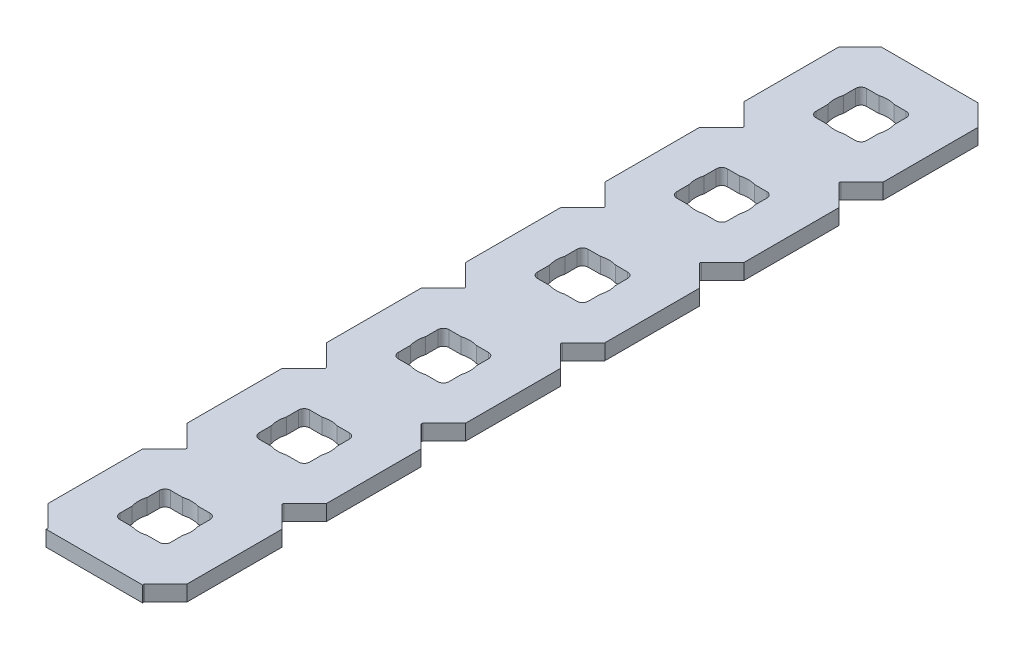
from build123d import *

# Parameters (mm, degrees)
BOSS_EXTRUDE1_DEPTH = 1.4224
SKETCH2_R           = 2.413
CUT_EXTRUDE1_DEPTH  = 2.54
LPATTERN1_COUNT     = 25
LPATTERN1_PITCH     = 12.7
SKETCH3_W           = 12.7
SKETCH3_H           = 63.589802561
CUT_EXTRUDE2_DEPTH  = 2.4224
SKETCH4_W           = 31.160114054
SKETCH4_H           = 185.655670282
CUT_EXTRUDE3_DEPTH  = 2.54


with BuildPart() as part:
    # Sketch1 → Boss-Extrude1 (new body)
    with BuildSketch(Plane.XZ):
        with BuildLine():
            Line((12.7, -302.773014945), (12.7, -294.126985055))
            Line((12.7, -294.126985055), (10.762817506, -292.189802561))
            ThreePointArc((10.762817506, -292.189802561), (10.725620068, -292.1), (10.762817506, -292.010197439))
            Line((10.762817506, -292.010197439), (12.7, -290.073014945))
            Line((12.7, -290.073014945), (12.7, -281.426985055))
            Line((12.7, -281.426985055), (10.762817506, -279.489802561))
            ThreePointArc((10.762817506, -279.489802561), (10.725620068, -279.4), (10.762817506, -279.310197439))
            Line((10.762817506, -279.310197439), (12.7, -277.373014945))
            Line((12.7, -277.373014945), (12.7, -268.726985055))
            Line((12.7, -268.726985055), (10.762817506, -266.789802561))
            ThreePointArc((10.762817506, -266.789802561), (10.725620068, -266.7), (10.762817506, -266.610197439))
            Line((10.762817506, -266.610197439), (12.7, -264.673014945))
            Line((12.7, -264.673014945), (12.7, -256.026985055))
            Line((12.7, -256.026985055), (10.762817506, -254.089802561))
            ThreePointArc((10.762817506, -254.089802561), (10.725620068, -254), (10.762817506, -253.910197439))
            Line((10.762817506, -253.910197439), (12.7, -251.973014945))
            Line((12.7, -251.973014945), (12.7, -243.326985055))
            Line((12.7, -243.326985055), (10.762817506, -241.389802561))
            ThreePointArc((10.762817506, -241.389802561), (10.725620068, -241.3), (10.762817506, -241.210197439))
            Line((10.762817506, -241.210197439), (12.7, -239.273014945))
            Line((12.7, -239.273014945), (12.7, -230.626985055))
            Line((12.7, -230.626985055), (10.762817506, -228.689802561))
            ThreePointArc((10.762817506, -228.689802561), (10.725620068, -228.6), (10.762817506, -228.510197439))
            Line((10.762817506, -228.510197439), (12.7, -226.573014945))
            Line((12.7, -226.573014945), (12.7, -217.926985055))
            Line((12.7, -217.926985055), (10.762817506, -215.989802561))
            ThreePointArc((10.762817506, -215.989802561), (10.725620068, -215.9), (10.762817506, -215.810197439))
            Line((10.762817506, -215.810197439), (12.7, -213.873014945))
            Line((12.7, -213.873014945), (12.7, -205.226985055))
            Line((12.7, -205.226985055), (10.762817506, -203.289802561))
            ThreePointArc((10.762817506, -203.289802561), (10.725620068, -203.2), (10.762817506, -203.110197439))
            Line((10.762817506, -203.110197439), (12.7, -201.173014945))
            Line((12.7, -201.173014945), (12.7, -192.526985055))
            Line((12.7, -192.526985055), (10.762817506, -190.589802561))
            ThreePointArc((10.762817506, -190.589802561), (10.725620068, -190.5), (10.762817506, -190.410197439))
            Line((10.762817506, -190.410197439), (12.7, -188.473014945))
            Line((12.7, -188.473014945), (12.7, -179.826985055))
            Line((12.7, -179.826985055), (10.762817506, -177.889802561))
            ThreePointArc((10.762817506, -177.889802561), (10.725620068, -177.8), (10.762817506, -177.710197439))
            Line((10.762817506, -177.710197439), (12.7, -175.773014945))
            Line((12.7, -175.773014945), (12.7, -167.126985055))
            Line((12.7, -167.126985055), (10.762817506, -165.189802561))
            ThreePointArc((10.762817506, -165.189802561), (10.725620068, -165.1), (10.762817506, -165.010197439))
            Line((10.762817506, -165.010197439), (12.7, -163.073014945))
            Line((12.7, -163.073014945), (12.7, -154.426985055))
            Line((12.7, -154.426985055), (10.762817506, -152.489802561))
            ThreePointArc((10.762817506, -152.489802561), (10.725620068, -152.4), (10.762817506, -152.310197439))
            Line((10.762817506, -152.310197439), (12.7, -150.373014945))
            Line((12.7, -150.373014945), (12.7, -141.726985055))
            Line((12.7, -141.726985055), (10.762817506, -139.789802561))
            ThreePointArc((10.762817506, -139.789802561), (10.725620068, -139.7), (10.762817506, -139.610197439))
            Line((10.762817506, -139.610197439), (12.7, -137.673014945))
            Line((12.7, -137.673014945), (12.7, -129.026985055))
            Line((12.7, -129.026985055), (10.762817506, -127.089802561))
            ThreePointArc((10.762817506, -127.089802561), (10.725620068, -127), (10.762817506, -126.910197439))
            Line((10.762817506, -126.910197439), (12.7, -124.973014945))
            Line((12.7, -124.973014945), (12.7, -116.326985055))
            Line((12.7, -116.326985055), (10.762817506, -114.389802561))
            ThreePointArc((10.762817506, -114.389802561), (10.725620068, -114.3), (10.762817506, -114.210197439))
            Line((10.762817506, -114.210197439), (12.7, -112.273014945))
            Line((12.7, -112.273014945), (12.7, -103.626985055))
            Line((12.7, -103.626985055), (10.762817506, -101.689802561))
            ThreePointArc((10.762817506, -101.689802561), (10.725620068, -101.6), (10.762817506, -101.510197439))
            Line((10.762817506, -101.510197439), (12.7, -99.573014945))
            Line((12.7, -99.573014945), (12.7, -90.926985055))
            Line((12.7, -90.926985055), (10.762817506, -88.989802561))
            ThreePointArc((10.762817506, -88.989802561), (10.725620068, -88.9), (10.762817506, -88.810197439))
            Line((10.762817506, -88.810197439), (12.7, -86.873014945))
            Line((12.7, -86.873014945), (12.7, -78.226985055))
            Line((12.7, -78.226985055), (10.762817506, -76.289802561))
            ThreePointArc((10.762817506, -76.289802561), (10.725620068, -76.2), (10.762817506, -76.110197439))
            Line((10.762817506, -76.110197439), (12.7, -74.173014945))
            Line((12.7, -74.173014945), (12.7, -65.526985055))
            Line((12.7, -65.526985055), (10.762817506, -63.589802561))
            ThreePointArc((10.762817506, -63.589802561), (10.725620068, -63.5), (10.762817506, -63.410197439))
            Line((10.762817506, -63.410197439), (12.7, -61.473014945))
            Line((12.7, -61.473014945), (12.7, -52.826985055))
            Line((12.7, -52.826985055), (10.762817506, -50.889802561))
            ThreePointArc((10.762817506, -50.889802561), (10.725620068, -50.8), (10.762817506, -50.710197439))
            Line((10.762817506, -50.710197439), (12.7, -48.773014945))
            Line((12.7, -48.773014945), (12.7, -40.126985055))
            Line((12.7, -40.126985055), (10.762817506, -38.189802561))
            ThreePointArc((10.762817506, -38.189802561), (10.725620068, -38.1), (10.762817506, -38.010197439))
            Line((10.762817506, -38.010197439), (12.7, -36.073014945))
            Line((12.7, -36.073014945), (12.7, -27.426985055))
            Line((12.7, -27.426985055), (10.762817506, -25.489802561))
            ThreePointArc((10.762817506, -25.489802561), (10.725620068, -25.4), (10.762817506, -25.310197439))
            Line((10.762817506, -25.310197439), (12.7, -23.373014945))
            Line((12.7, -23.373014945), (12.7, -14.726985055))
            Line((12.7, -14.726985055), (10.762817506, -12.789802561))
            ThreePointArc((10.762817506, -12.789802561), (10.725620068, -12.7), (10.762817506, -12.610197439))
            Line((10.762817506, -12.610197439), (12.7, -10.673014945))
            Line((12.7, -10.673014945), (12.7, -2.032))
            Line((12.7, -2.032), (10.668, 0))
            Line((10.668, 0), (2.032, 0))
            Line((2.032, 0), (0, -2.032))
            Line((0, -2.032), (0, -10.673014945))
            Line((0, -10.673014945), (1.937182494, -12.610197439))
            ThreePointArc((1.937182494, -12.610197439), (1.974379932, -12.7), (1.937182494, -12.789802561))
            Line((1.937182494, -12.789802561), (0, -14.726985055))
            Line((0, -14.726985055), (0, -23.373014945))
            Line((0, -23.373014945), (1.937182494, -25.310197439))
            ThreePointArc((1.937182494, -25.310197439), (1.974379932, -25.4), (1.937182494, -25.489802561))
            Line((1.937182494, -25.489802561), (0, -27.426985055))
            Line((0, -27.426985055), (0, -36.073014945))
            Line((0, -36.073014945), (1.937182494, -38.010197439))
            ThreePointArc((1.937182494, -38.010197439), (1.974379932, -38.1), (1.937182494, -38.189802561))
            Line((1.937182494, -38.189802561), (0, -40.126985055))
            Line((0, -40.126985055), (0, -48.773014945))
            Line((0, -48.773014945), (1.937182494, -50.710197439))
            ThreePointArc((1.937182494, -50.710197439), (1.974379932, -50.8), (1.937182494, -50.889802561))
            Line((1.937182494, -50.889802561), (0, -52.826985055))
            Line((0, -52.826985055), (0, -61.473014945))
            Line((0, -61.473014945), (1.937182494, -63.410197439))
            ThreePointArc((1.937182494, -63.410197439), (1.974379932, -63.5), (1.937182494, -63.589802561))
            Line((1.937182494, -63.589802561), (0, -65.526985055))
            Line((0, -65.526985055), (0, -74.173014945))
            Line((0, -74.173014945), (1.937182494, -76.110197439))
            ThreePointArc((1.937182494, -76.110197439), (1.974379932, -76.2), (1.937182494, -76.289802561))
            Line((1.937182494, -76.289802561), (0, -78.226985055))
            Line((0, -78.226985055), (0, -86.873014945))
            Line((0, -86.873014945), (1.937182494, -88.810197439))
            ThreePointArc((1.937182494, -88.810197439), (1.974379932, -88.9), (1.937182494, -88.989802561))
            Line((1.937182494, -88.989802561), (0, -90.926985055))
            Line((0, -90.926985055), (0, -99.573014945))
            Line((0, -99.573014945), (1.937182494, -101.510197439))
            ThreePointArc((1.937182494, -101.510197439), (1.974379932, -101.6), (1.937182494, -101.689802561))
            Line((1.937182494, -101.689802561), (0, -103.626985055))
            Line((0, -103.626985055), (0, -112.273014945))
            Line((0, -112.273014945), (1.937182494, -114.210197439))
            ThreePointArc((1.937182494, -114.210197439), (1.974379932, -114.3), (1.937182494, -114.389802561))
            Line((1.937182494, -114.389802561), (0, -116.326985055))
            Line((0, -116.326985055), (0, -124.973014945))
            Line((0, -124.973014945), (1.937182494, -126.910197439))
            ThreePointArc((1.937182494, -126.910197439), (1.974379932, -127), (1.937182494, -127.089802561))
            Line((1.937182494, -127.089802561), (0, -129.026985055))
            Line((0, -129.026985055), (0, -137.673014945))
            Line((0, -137.673014945), (1.937182494, -139.610197439))
            ThreePointArc((1.937182494, -139.610197439), (1.974379932, -139.7), (1.937182494, -139.789802561))
            Line((1.937182494, -139.789802561), (0, -141.726985055))
            Line((0, -141.726985055), (0, -150.373014945))
            Line((0, -150.373014945), (1.937182494, -152.310197439))
            ThreePointArc((1.937182494, -152.310197439), (1.974379932, -152.4), (1.937182494, -152.489802561))
            Line((1.937182494, -152.489802561), (0, -154.426985055))
            Line((0, -154.426985055), (0, -163.073014945))
            Line((0, -163.073014945), (1.937182494, -165.010197439))
            ThreePointArc((1.937182494, -165.010197439), (1.974379932, -165.1), (1.937182494, -165.189802561))
            Line((1.937182494, -165.189802561), (0, -167.126985055))
            Line((0, -167.126985055), (0, -175.773014945))
            Line((0, -175.773014945), (1.937182494, -177.710197439))
            ThreePointArc((1.937182494, -177.710197439), (1.974379932, -177.8), (1.937182494, -177.889802561))
            Line((1.937182494, -177.889802561), (0, -179.826985055))
            Line((0, -179.826985055), (0, -188.473014945))
            Line((0, -188.473014945), (1.937182494, -190.410197439))
            ThreePointArc((1.937182494, -190.410197439), (1.974379932, -190.5), (1.937182494, -190.589802561))
            Line((1.937182494, -190.589802561), (0, -192.526985055))
            Line((0, -192.526985055), (0, -201.173014945))
            Line((0, -201.173014945), (1.937182494, -203.110197439))
            ThreePointArc((1.937182494, -203.110197439), (1.974379932, -203.2), (1.937182494, -203.289802561))
            Line((1.937182494, -203.289802561), (0, -205.226985055))
            Line((0, -205.226985055), (0, -213.873014945))
            Line((0, -213.873014945), (1.937182494, -215.810197439))
            ThreePointArc((1.937182494, -215.810197439), (1.974379932, -215.9), (1.937182494, -215.989802561))
            Line((1.937182494, -215.989802561), (0, -217.926985055))
            Line((0, -217.926985055), (0, -226.573014945))
            Line((0, -226.573014945), (1.937182494, -228.510197439))
            ThreePointArc((1.937182494, -228.510197439), (1.974379932, -228.6), (1.937182494, -228.689802561))
            Line((1.937182494, -228.689802561), (0, -230.626985055))
            Line((0, -230.626985055), (0, -239.273014945))
            Line((0, -239.273014945), (1.937182494, -241.210197439))
            ThreePointArc((1.937182494, -241.210197439), (1.974379932, -241.3), (1.937182494, -241.389802561))
            Line((1.937182494, -241.389802561), (0, -243.326985055))
            Line((0, -243.326985055), (0, -251.973014945))
            Line((0, -251.973014945), (1.937182494, -253.910197439))
            ThreePointArc((1.937182494, -253.910197439), (1.974379932, -254), (1.937182494, -254.089802561))
            Line((1.937182494, -254.089802561), (0, -256.026985055))
            Line((0, -256.026985055), (0, -264.673014945))
            Line((0, -264.673014945), (1.937182494, -266.610197439))
            ThreePointArc((1.937182494, -266.610197439), (1.974379932, -266.7), (1.937182494, -266.789802561))
            Line((1.937182494, -266.789802561), (0, -268.726985055))
            Line((0, -268.726985055), (0, -277.373014945))
            Line((0, -277.373014945), (1.937182494, -279.310197439))
            ThreePointArc((1.937182494, -279.310197439), (1.974379932, -279.4), (1.937182494, -279.489802561))
            Line((1.937182494, -279.489802561), (0, -281.426985055))
            Line((0, -281.426985055), (0, -290.073014945))
            Line((0, -290.073014945), (1.937182494, -292.010197439))
            ThreePointArc((1.937182494, -292.010197439), (1.974379932, -292.1), (1.937182494, -292.189802561))
            Line((1.937182494, -292.189802561), (0, -294.126985055))
            Line((0, -294.126985055), (0, -302.773014945))
            Line((0, -302.773014945), (1.937182494, -304.710197439))
            ThreePointArc((1.937182494, -304.710197439), (1.974379932, -304.8), (1.937182494, -304.889802561))
            Line((1.937182494, -304.889802561), (0, -306.826985055))
            Line((0, -306.826985055), (0, -315.468))
            Line((0, -315.468), (2.032, -317.5))
            Line((2.032, -317.5), (10.668, -317.5))
            Line((10.668, -317.5), (12.7, -315.468))
            Line((12.7, -315.468), (12.7, -306.826985055))
            Line((12.7, -306.826985055), (10.762817506, -304.889802561))
            ThreePointArc((10.762817506, -304.889802561), (10.725620068, -304.8), (10.762817506, -304.710197439))
            Line((10.762817506, -304.710197439), (12.7, -302.773014945))
        make_face()
        with BuildLine():
            Line((4.5466, -308.8386), (8.1534, -308.8386))
            ThreePointArc((8.1534, -308.8386), (8.512610245, -308.987389755), (8.6614, -309.3466))
            Line((8.6614, -309.3466), (8.6614, -312.9534))
            ThreePointArc((8.6614, -312.9534), (8.512610245, -313.312610245), (8.1534, -313.4614))
            Line((8.1534, -313.4614), (4.5466, -313.4614))
            ThreePointArc((4.5466, -313.4614), (4.187389755, -313.312610245), (4.0386, -312.9534))
            Line((4.0386, -312.9534), (4.0386, -309.3466))
            ThreePointArc((4.0386, -309.3466), (4.187389755, -308.987389755), (4.5466, -308.8386))
        make_face(mode=Mode.SUBTRACT)
        with BuildLine():
            Line((4.5466, -296.1386), (8.1534, -296.1386))
            ThreePointArc((8.1534, -296.1386), (8.512610245, -296.287389755), (8.6614, -296.6466))
            Line((8.6614, -296.6466), (8.6614, -300.2534))
            ThreePointArc((8.6614, -300.2534), (8.512610245, -300.612610245), (8.1534, -300.7614))
            Line((8.1534, -300.7614), (4.5466, -300.7614))
            ThreePointArc((4.5466, -300.7614), (4.187389755, -300.612610245), (4.0386, -300.2534))
            Line((4.0386, -300.2534), (4.0386, -296.6466))
            ThreePointArc((4.0386, -296.6466), (4.187389755, -296.287389755), (4.5466, -296.1386))
        make_face(mode=Mode.SUBTRACT)
        with BuildLine():
            Line((4.5466, -283.4386), (8.1534, -283.4386))
            ThreePointArc((8.1534, -283.4386), (8.512610245, -283.587389755), (8.6614, -283.9466))
            Line((8.6614, -283.9466), (8.6614, -287.5534))
            ThreePointArc((8.6614, -287.5534), (8.512610245, -287.912610245), (8.1534, -288.0614))
            Line((8.1534, -288.0614), (4.5466, -288.0614))
            ThreePointArc((4.5466, -288.0614), (4.187389755, -287.912610245), (4.0386, -287.5534))
            Line((4.0386, -287.5534), (4.0386, -283.9466))
            ThreePointArc((4.0386, -283.9466), (4.187389755, -283.587389755), (4.5466, -283.4386))
        make_face(mode=Mode.SUBTRACT)
        with BuildLine():
            Line((4.5466, -270.7386), (8.1534, -270.7386))
            ThreePointArc((8.1534, -270.7386), (8.512610245, -270.887389755), (8.6614, -271.2466))
            Line((8.6614, -271.2466), (8.6614, -274.8534))
            ThreePointArc((8.6614, -274.8534), (8.512610245, -275.212610245), (8.1534, -275.3614))
            Line((8.1534, -275.3614), (4.5466, -275.3614))
            ThreePointArc((4.5466, -275.3614), (4.187389755, -275.212610245), (4.0386, -274.8534))
            Line((4.0386, -274.8534), (4.0386, -271.2466))
            ThreePointArc((4.0386, -271.2466), (4.187389755, -270.887389755), (4.5466, -270.7386))
        make_face(mode=Mode.SUBTRACT)
        with BuildLine():
            Line((4.5466, -258.0386), (8.1534, -258.0386))
            ThreePointArc((8.1534, -258.0386), (8.512610245, -258.187389755), (8.6614, -258.5466))
            Line((8.6614, -258.5466), (8.6614, -262.1534))
            ThreePointArc((8.6614, -262.1534), (8.512610245, -262.512610245), (8.1534, -262.6614))
            Line((8.1534, -262.6614), (4.5466, -262.6614))
            ThreePointArc((4.5466, -262.6614), (4.187389755, -262.512610245), (4.0386, -262.1534))
            Line((4.0386, -262.1534), (4.0386, -258.5466))
            ThreePointArc((4.0386, -258.5466), (4.187389755, -258.187389755), (4.5466, -258.0386))
        make_face(mode=Mode.SUBTRACT)
        with BuildLine():
            Line((4.5466, -245.3386), (8.1534, -245.3386))
            ThreePointArc((8.1534, -245.3386), (8.512610245, -245.487389755), (8.6614, -245.8466))
            Line((8.6614, -245.8466), (8.6614, -249.4534))
            ThreePointArc((8.6614, -249.4534), (8.512610245, -249.812610245), (8.1534, -249.9614))
            Line((8.1534, -249.9614), (4.5466, -249.9614))
            ThreePointArc((4.5466, -249.9614), (4.187389755, -249.812610245), (4.0386, -249.4534))
            Line((4.0386, -249.4534), (4.0386, -245.8466))
            ThreePointArc((4.0386, -245.8466), (4.187389755, -245.487389755), (4.5466, -245.3386))
        make_face(mode=Mode.SUBTRACT)
        with BuildLine():
            Line((4.5466, -232.6386), (8.1534, -232.6386))
            ThreePointArc((8.1534, -232.6386), (8.512610245, -232.787389755), (8.6614, -233.1466))
            Line((8.6614, -233.1466), (8.6614, -236.7534))
            ThreePointArc((8.6614, -236.7534), (8.512610245, -237.112610245), (8.1534, -237.2614))
            Line((8.1534, -237.2614), (4.5466, -237.2614))
            ThreePointArc((4.5466, -237.2614), (4.187389755, -237.112610245), (4.0386, -236.7534))
            Line((4.0386, -236.7534), (4.0386, -233.1466))
            ThreePointArc((4.0386, -233.1466), (4.187389755, -232.787389755), (4.5466, -232.6386))
        make_face(mode=Mode.SUBTRACT)
        with BuildLine():
            Line((4.5466, -219.9386), (8.1534, -219.9386))
            ThreePointArc((8.1534, -219.9386), (8.512610245, -220.087389755), (8.6614, -220.4466))
            Line((8.6614, -220.4466), (8.6614, -224.0534))
            ThreePointArc((8.6614, -224.0534), (8.512610245, -224.412610245), (8.1534, -224.5614))
            Line((8.1534, -224.5614), (4.5466, -224.5614))
            ThreePointArc((4.5466, -224.5614), (4.187389755, -224.412610245), (4.0386, -224.0534))
            Line((4.0386, -224.0534), (4.0386, -220.4466))
            ThreePointArc((4.0386, -220.4466), (4.187389755, -220.087389755), (4.5466, -219.9386))
        make_face(mode=Mode.SUBTRACT)
        with BuildLine():
            Line((4.5466, -207.2386), (8.1534, -207.2386))
            ThreePointArc((8.1534, -207.2386), (8.512610245, -207.387389755), (8.6614, -207.7466))
            Line((8.6614, -207.7466), (8.6614, -211.3534))
            ThreePointArc((8.6614, -211.3534), (8.512610245, -211.712610245), (8.1534, -211.8614))
            Line((8.1534, -211.8614), (4.5466, -211.8614))
            ThreePointArc((4.5466, -211.8614), (4.187389755, -211.712610245), (4.0386, -211.3534))
            Line((4.0386, -211.3534), (4.0386, -207.7466))
            ThreePointArc((4.0386, -207.7466), (4.187389755, -207.387389755), (4.5466, -207.2386))
        make_face(mode=Mode.SUBTRACT)
        with BuildLine():
            Line((4.5466, -194.5386), (8.1534, -194.5386))
            ThreePointArc((8.1534, -194.5386), (8.512610245, -194.687389755), (8.6614, -195.0466))
            Line((8.6614, -195.0466), (8.6614, -198.6534))
            ThreePointArc((8.6614, -198.6534), (8.512610245, -199.012610245), (8.1534, -199.1614))
            Line((8.1534, -199.1614), (4.5466, -199.1614))
            ThreePointArc((4.5466, -199.1614), (4.187389755, -199.012610245), (4.0386, -198.6534))
            Line((4.0386, -198.6534), (4.0386, -195.0466))
            ThreePointArc((4.0386, -195.0466), (4.187389755, -194.687389755), (4.5466, -194.5386))
        make_face(mode=Mode.SUBTRACT)
        with BuildLine():
            Line((4.5466, -181.8386), (8.1534, -181.8386))
            ThreePointArc((8.1534, -181.8386), (8.512610245, -181.987389755), (8.6614, -182.3466))
            Line((8.6614, -182.3466), (8.6614, -185.9534))
            ThreePointArc((8.6614, -185.9534), (8.512610245, -186.312610245), (8.1534, -186.4614))
            Line((8.1534, -186.4614), (4.5466, -186.4614))
            ThreePointArc((4.5466, -186.4614), (4.187389755, -186.312610245), (4.0386, -185.9534))
            Line((4.0386, -185.9534), (4.0386, -182.3466))
            ThreePointArc((4.0386, -182.3466), (4.187389755, -181.987389755), (4.5466, -181.8386))
        make_face(mode=Mode.SUBTRACT)
        with BuildLine():
            Line((4.5466, -169.1386), (8.1534, -169.1386))
            ThreePointArc((8.1534, -169.1386), (8.512610245, -169.287389755), (8.6614, -169.6466))
            Line((8.6614, -169.6466), (8.6614, -173.2534))
            ThreePointArc((8.6614, -173.2534), (8.512610245, -173.612610245), (8.1534, -173.7614))
            Line((8.1534, -173.7614), (4.5466, -173.7614))
            ThreePointArc((4.5466, -173.7614), (4.187389755, -173.612610245), (4.0386, -173.2534))
            Line((4.0386, -173.2534), (4.0386, -169.6466))
            ThreePointArc((4.0386, -169.6466), (4.187389755, -169.287389755), (4.5466, -169.1386))
        make_face(mode=Mode.SUBTRACT)
        with BuildLine():
            Line((4.5466, -156.4386), (8.1534, -156.4386))
            ThreePointArc((8.1534, -156.4386), (8.512610245, -156.587389755), (8.6614, -156.9466))
            Line((8.6614, -156.9466), (8.6614, -160.5534))
            ThreePointArc((8.6614, -160.5534), (8.512610245, -160.912610245), (8.1534, -161.0614))
            Line((8.1534, -161.0614), (4.5466, -161.0614))
            ThreePointArc((4.5466, -161.0614), (4.187389755, -160.912610245), (4.0386, -160.5534))
            Line((4.0386, -160.5534), (4.0386, -156.9466))
            ThreePointArc((4.0386, -156.9466), (4.187389755, -156.587389755), (4.5466, -156.4386))
        make_face(mode=Mode.SUBTRACT)
        with BuildLine():
            Line((4.5466, -143.7386), (8.1534, -143.7386))
            ThreePointArc((8.1534, -143.7386), (8.512610245, -143.887389755), (8.6614, -144.2466))
            Line((8.6614, -144.2466), (8.6614, -147.8534))
            ThreePointArc((8.6614, -147.8534), (8.512610245, -148.212610245), (8.1534, -148.3614))
            Line((8.1534, -148.3614), (4.5466, -148.3614))
            ThreePointArc((4.5466, -148.3614), (4.187389755, -148.212610245), (4.0386, -147.8534))
            Line((4.0386, -147.8534), (4.0386, -144.2466))
            ThreePointArc((4.0386, -144.2466), (4.187389755, -143.887389755), (4.5466, -143.7386))
        make_face(mode=Mode.SUBTRACT)
        with BuildLine():
            Line((4.5466, -131.0386), (8.1534, -131.0386))
            ThreePointArc((8.1534, -131.0386), (8.512610245, -131.187389755), (8.6614, -131.5466))
            Line((8.6614, -131.5466), (8.6614, -135.1534))
            ThreePointArc((8.6614, -135.1534), (8.512610245, -135.512610245), (8.1534, -135.6614))
            Line((8.1534, -135.6614), (4.5466, -135.6614))
            ThreePointArc((4.5466, -135.6614), (4.187389755, -135.512610245), (4.0386, -135.1534))
            Line((4.0386, -135.1534), (4.0386, -131.5466))
            ThreePointArc((4.0386, -131.5466), (4.187389755, -131.187389755), (4.5466, -131.0386))
        make_face(mode=Mode.SUBTRACT)
        with BuildLine():
            Line((4.5466, -118.3386), (8.1534, -118.3386))
            ThreePointArc((8.1534, -118.3386), (8.512610245, -118.487389755), (8.6614, -118.8466))
            Line((8.6614, -118.8466), (8.6614, -122.4534))
            ThreePointArc((8.6614, -122.4534), (8.512610245, -122.812610245), (8.1534, -122.9614))
            Line((8.1534, -122.9614), (4.5466, -122.9614))
            ThreePointArc((4.5466, -122.9614), (4.187389755, -122.812610245), (4.0386, -122.4534))
            Line((4.0386, -122.4534), (4.0386, -118.8466))
            ThreePointArc((4.0386, -118.8466), (4.187389755, -118.487389755), (4.5466, -118.3386))
        make_face(mode=Mode.SUBTRACT)
        with BuildLine():
            Line((4.5466, -105.6386), (8.1534, -105.6386))
            ThreePointArc((8.1534, -105.6386), (8.512610245, -105.787389755), (8.6614, -106.1466))
            Line((8.6614, -106.1466), (8.6614, -109.7534))
            ThreePointArc((8.6614, -109.7534), (8.512610245, -110.112610245), (8.1534, -110.2614))
            Line((8.1534, -110.2614), (4.5466, -110.2614))
            ThreePointArc((4.5466, -110.2614), (4.187389755, -110.112610245), (4.0386, -109.7534))
            Line((4.0386, -109.7534), (4.0386, -106.1466))
            ThreePointArc((4.0386, -106.1466), (4.187389755, -105.787389755), (4.5466, -105.6386))
        make_face(mode=Mode.SUBTRACT)
        with BuildLine():
            Line((4.5466, -92.9386), (8.1534, -92.9386))
            ThreePointArc((8.1534, -92.9386), (8.512610245, -93.087389755), (8.6614, -93.4466))
            Line((8.6614, -93.4466), (8.6614, -97.0534))
            ThreePointArc((8.6614, -97.0534), (8.512610245, -97.412610245), (8.1534, -97.5614))
            Line((8.1534, -97.5614), (4.5466, -97.5614))
            ThreePointArc((4.5466, -97.5614), (4.187389755, -97.412610245), (4.0386, -97.0534))
            Line((4.0386, -97.0534), (4.0386, -93.4466))
            ThreePointArc((4.0386, -93.4466), (4.187389755, -93.087389755), (4.5466, -92.9386))
        make_face(mode=Mode.SUBTRACT)
        with BuildLine():
            Line((4.5466, -80.2386), (8.1534, -80.2386))
            ThreePointArc((8.1534, -80.2386), (8.512610245, -80.387389755), (8.6614, -80.7466))
            Line((8.6614, -80.7466), (8.6614, -84.3534))
            ThreePointArc((8.6614, -84.3534), (8.512610245, -84.712610245), (8.1534, -84.8614))
            Line((8.1534, -84.8614), (4.5466, -84.8614))
            ThreePointArc((4.5466, -84.8614), (4.187389755, -84.712610245), (4.0386, -84.3534))
            Line((4.0386, -84.3534), (4.0386, -80.7466))
            ThreePointArc((4.0386, -80.7466), (4.187389755, -80.387389755), (4.5466, -80.2386))
        make_face(mode=Mode.SUBTRACT)
        with BuildLine():
            Line((4.5466, -67.5386), (8.1534, -67.5386))
            ThreePointArc((8.1534, -67.5386), (8.512610245, -67.687389755), (8.6614, -68.0466))
            Line((8.6614, -68.0466), (8.6614, -71.6534))
            ThreePointArc((8.6614, -71.6534), (8.512610245, -72.012610245), (8.1534, -72.1614))
            Line((8.1534, -72.1614), (4.5466, -72.1614))
            ThreePointArc((4.5466, -72.1614), (4.187389755, -72.012610245), (4.0386, -71.6534))
            Line((4.0386, -71.6534), (4.0386, -68.0466))
            ThreePointArc((4.0386, -68.0466), (4.187389755, -67.687389755), (4.5466, -67.5386))
        make_face(mode=Mode.SUBTRACT)
        with BuildLine():
            Line((4.5466, -54.8386), (8.1534, -54.8386))
            ThreePointArc((8.1534, -54.8386), (8.512610245, -54.987389755), (8.6614, -55.3466))
            Line((8.6614, -55.3466), (8.6614, -58.9534))
            ThreePointArc((8.6614, -58.9534), (8.512610245, -59.312610245), (8.1534, -59.4614))
            Line((8.1534, -59.4614), (4.5466, -59.4614))
            ThreePointArc((4.5466, -59.4614), (4.187389755, -59.312610245), (4.0386, -58.9534))
            Line((4.0386, -58.9534), (4.0386, -55.3466))
            ThreePointArc((4.0386, -55.3466), (4.187389755, -54.987389755), (4.5466, -54.8386))
        make_face(mode=Mode.SUBTRACT)
        with BuildLine():
            Line((4.5466, -42.1386), (8.1534, -42.1386))
            ThreePointArc((8.1534, -42.1386), (8.512610245, -42.287389755), (8.6614, -42.6466))
            Line((8.6614, -42.6466), (8.6614, -46.2534))
            ThreePointArc((8.6614, -46.2534), (8.512610245, -46.612610245), (8.1534, -46.7614))
            Line((8.1534, -46.7614), (4.5466, -46.7614))
            ThreePointArc((4.5466, -46.7614), (4.187389755, -46.612610245), (4.0386, -46.2534))
            Line((4.0386, -46.2534), (4.0386, -42.6466))
            ThreePointArc((4.0386, -42.6466), (4.187389755, -42.287389755), (4.5466, -42.1386))
        make_face(mode=Mode.SUBTRACT)
        with BuildLine():
            Line((4.5466, -29.4386), (8.1534, -29.4386))
            ThreePointArc((8.1534, -29.4386), (8.512610245, -29.587389755), (8.6614, -29.9466))
            Line((8.6614, -29.9466), (8.6614, -33.5534))
            ThreePointArc((8.6614, -33.5534), (8.512610245, -33.912610245), (8.1534, -34.0614))
            Line((8.1534, -34.0614), (4.5466, -34.0614))
            ThreePointArc((4.5466, -34.0614), (4.187389755, -33.912610245), (4.0386, -33.5534))
            Line((4.0386, -33.5534), (4.0386, -29.9466))
            ThreePointArc((4.0386, -29.9466), (4.187389755, -29.587389755), (4.5466, -29.4386))
        make_face(mode=Mode.SUBTRACT)
        with BuildLine():
            Line((8.1534, -8.6614), (4.5466, -8.6614))
            ThreePointArc((4.5466, -8.6614), (4.187389755, -8.512610245), (4.0386, -8.1534))
            Line((4.0386, -8.1534), (4.0386, -4.5466))
            ThreePointArc((4.0386, -4.5466), (4.187389755, -4.187389755), (4.5466, -4.0386))
            Line((4.5466, -4.0386), (8.1534, -4.0386))
            ThreePointArc((8.1534, -4.0386), (8.512610245, -4.187389755), (8.6614, -4.5466))
            Line((8.6614, -4.5466), (8.6614, -8.1534))
            ThreePointArc((8.6614, -8.1534), (8.512610245, -8.512610245), (8.1534, -8.6614))
        make_face(mode=Mode.SUBTRACT)
        with BuildLine():
            Line((4.0386, -20.8534), (4.0386, -17.2466))
            ThreePointArc((4.0386, -17.2466), (4.187389755, -16.887389755), (4.5466, -16.7386))
            Line((4.5466, -16.7386), (8.1534, -16.7386))
            ThreePointArc((8.1534, -16.7386), (8.512610245, -16.887389755), (8.6614, -17.2466))
            Line((8.6614, -17.2466), (8.6614, -20.8534))
            ThreePointArc((8.6614, -20.8534), (8.512610245, -21.212610245), (8.1534, -21.3614))
            Line((8.1534, -21.3614), (4.5466, -21.3614))
            ThreePointArc((4.5466, -21.3614), (4.187389755, -21.212610245), (4.0386, -20.8534))
        make_face(mode=Mode.SUBTRACT)
    extrude(amount=-BOSS_EXTRUDE1_DEPTH)

    # Sketch2 → Cut-Extrude1 (cut)
    with BuildSketch(Plane(origin=(0, 1.4224, 0), x_dir=(1, 0, 0), z_dir=(0, 1, 0))):
        with Locations((6.35, 6.35)):
            Circle(SKETCH2_R)
    cut_extrude1 = extrude(amount=-CUT_EXTRUDE1_DEPTH, mode=Mode.SUBTRACT)

    # LPattern1: Cut-Extrude1 ×25
    with Locations(*[(0, 0, -i * LPATTERN1_PITCH) for i in range(1, LPATTERN1_COUNT)]):
        add(cut_extrude1, mode=Mode.SUBTRACT)

    # Sketch3 → Cut-Extrude2 (cut, through all)
    with BuildSketch(Plane(origin=(0, 1.4224, 0), x_dir=(1, 0, 0), z_dir=(0, 1, 0))):
        with Locations((6.35, 285.70509872)):
            Rectangle(SKETCH3_W, SKETCH3_H)
    extrude(amount=-CUT_EXTRUDE2_DEPTH, mode=Mode.SUBTRACT)

    # Sketch4 → Cut-Extrude3 (cut)
    with BuildSketch(Plane(origin=(0, 1.4224, 0), x_dir=(1, 0, 0), z_dir=(0, 1, 0))):
        with Locations((8.31822068, 84.882362298)):
            Rectangle(SKETCH4_W, SKETCH4_H)
    extrude(amount=-CUT_EXTRUDE3_DEPTH, mode=Mode.SUBTRACT)


solid = part.part
